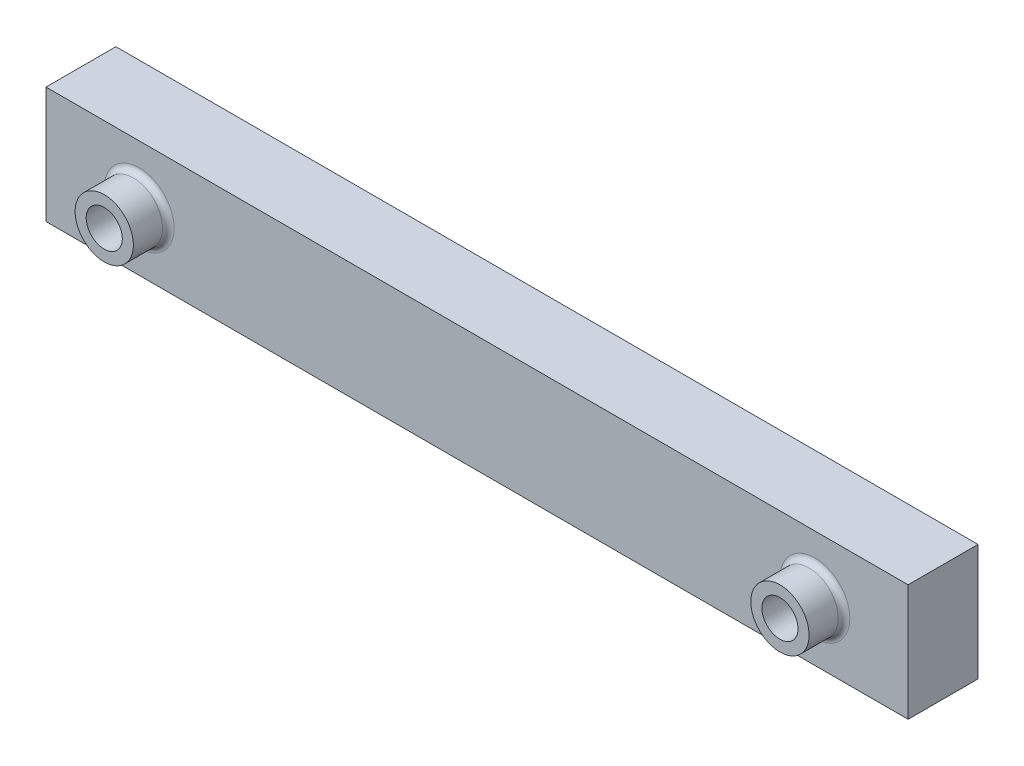
from build123d import *

# Parameters (mm, degrees)
SKETCH_1_W          = 74
SKETCH_1_H          = 10
EXTRUDE_1_DEPTH     = 6
SKETCH_2_R          = 1.55
CUT_EXTRUDE_1_DEPTH = 10
SKETCH_3_R          = 2.5
SKETCH_3_R_2        = 1.55
EXTRUDE_2_DEPTH     = 3
FILLET_5_R          = 0.5
FILLET_7_R          = 0.5


with BuildPart() as part:
    # 草图1 → 凸台-拉伸1 (new body)
    with BuildSketch(Plane.XY):
        with Locations((12.900383142, 1.335145162)):
            Rectangle(SKETCH_1_W, SKETCH_1_H)
    extrude(amount=EXTRUDE_1_DEPTH)

    # 草图2 → 切除-拉伸1 (cut)
    with BuildSketch(Plane.XY.offset(6)):
        with Locations((-16.099616858, 1.335145162)):
            Circle(SKETCH_2_R)
        with Locations((41.900383142, 1.335145162)):
            Circle(SKETCH_2_R)
    extrude(amount=-CUT_EXTRUDE_1_DEPTH, mode=Mode.SUBTRACT)

    # 草图3 → 凸台-拉伸2 (add)
    with BuildSketch(Plane.XY.offset(6)):
        with Locations((-16.099616858, 1.335145162)):
            Circle(SKETCH_3_R)
        with Locations((-16.099616858, 1.335145162)):
            Circle(SKETCH_3_R_2, mode=Mode.SUBTRACT)
        with Locations((41.900383142, 1.335145162)):
            Circle(SKETCH_3_R)
        with Locations((41.900383142, 1.335145162)):
            Circle(SKETCH_3_R_2, mode=Mode.SUBTRACT)
    extrude(amount=EXTRUDE_2_DEPTH)

    # 圆角5
    fillet_5_edges = [part.edges().sort_by_distance(p)[0] for p in [
        (39.400383142, 1.335145162, 6),
    ]]
    fillet(fillet_5_edges, radius=FILLET_5_R)

    # 圆角7
    fillet_7_edges = [part.edges().sort_by_distance(p)[0] for p in [
        (-18.599616858, 1.335145162, 6),
    ]]
    fillet(fillet_7_edges, radius=FILLET_7_R)


solid = part.part
